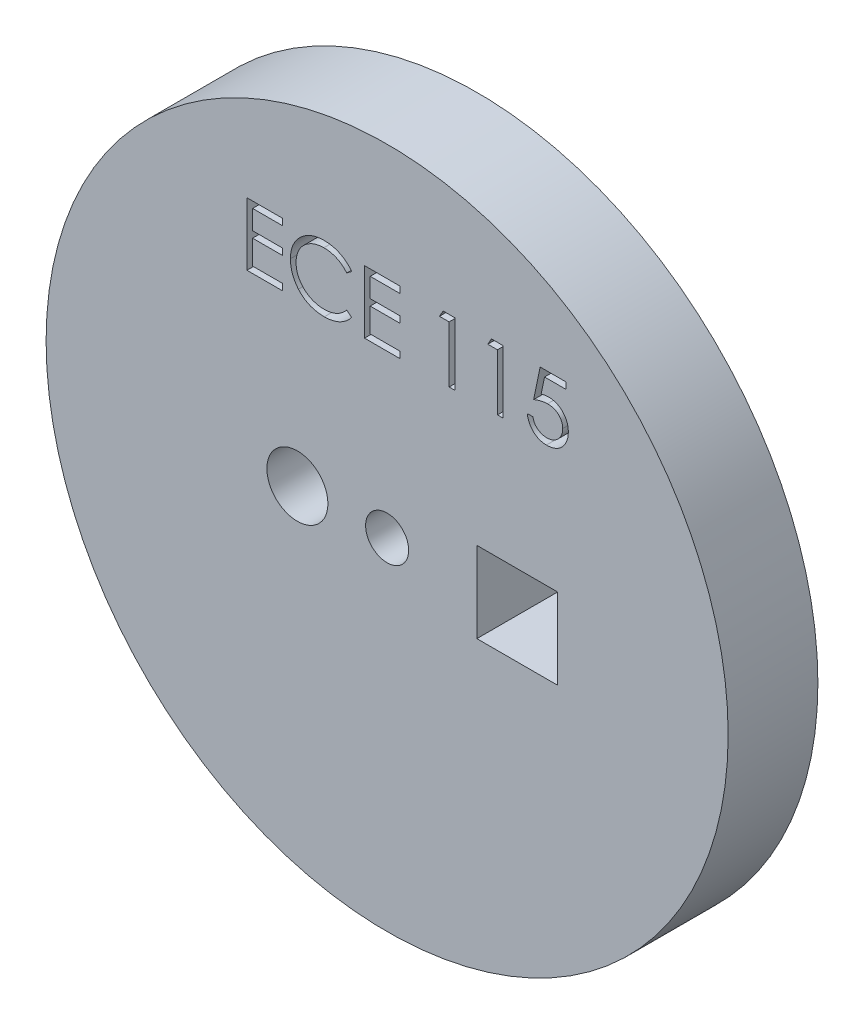
from build123d import *

# Parameters (mm, degrees)
SKETCH1_R           = 19
BOSS_EXTRUDE1_DEPTH = 5
SKETCH3_R           = 1.2
SKETCH3_R_2         = 1.7
SKETCH3_W           = 4.5
SKETCH3_H           = 4.5
CUT_EXTRUDE1_DEPTH  = 5
CUT_EXTRUDE2_DEPTH  = 5


with BuildPart() as part:
    # Sketch1 → Boss-Extrude1 (new body)
    with BuildSketch(Plane.XY):
        Circle(SKETCH1_R)
    extrude(amount=BOSS_EXTRUDE1_DEPTH)

    # Sketch3 → Cut-Extrude1 (cut)
    with BuildSketch(Plane.XY.offset(5)):
        Circle(SKETCH3_R)
        with Locations((-5, 0)):
            Circle(SKETCH3_R_2)
        with Locations((7.25, -0.109758643)):
            Rectangle(SKETCH3_W, SKETCH3_H)
    extrude(amount=-CUT_EXTRUDE1_DEPTH, mode=Mode.SUBTRACT)

    # Sketch4 → Cut-Extrude2 (cut)
    with BuildSketch(Plane.XY.offset(5)):
        Polygon((-7.809310087, 12.508270601), (-5.834951113, 12.508270601), (-5.834951113, 12.149296242), (-7.495207523, 12.149296242), (-7.495207523, 11.072373165), (-5.834951113, 11.072373165), (-5.834951113, 10.713398806), (-7.495207523, 10.713398806), (-7.495207523, 9.36724496), (-5.834951113, 9.36724496), (-5.834951113, 9.008270601), (-7.809310087, 9.008270601), align=None)
        with BuildLine():
            Line((-1.975976754, 11.866043037), (-2.250816497, 11.655706498))
            add(Edge.make_bspline(
                [(-2.250816497, 11.655706498), (-2.270422386, 11.679072468), (-2.309369832, 11.725489384), (-2.372029035, 11.790668928), (-2.437330678, 11.85173419), (-2.505249799, 11.908976069), (-2.577008919, 11.960392835), (-2.650869717, 12.008663938), (-2.728067762, 12.051931676), (-2.834819497, 12.104394662), (-2.974467345, 12.159140817), (-3.150262184, 12.205044048), (-3.333773283, 12.234265224), (-3.458970882, 12.237430066), (-3.522651433, 12.239039832)],
                knots=[0, 0, 0, 0, 9.1485e-05, 0.000181737, 0.000271024, 0.000359627, 0.000447979, 0.000535687, 0.000624217, 0.000713268, 0.000892422, 0.00107303, 0.001257466, 0.001448389, 0.001448389, 0.001448389, 0.001448389], degree=3))
            add(Edge.make_bspline(
                [(-3.522651433, 12.239039832), (-3.557734732, 12.238635869), (-3.627575725, 12.237831693), (-3.731224199, 12.227222568), (-3.83293725, 12.212311358), (-3.932648716, 12.190186035), (-4.030231674, 12.162213416), (-4.126324076, 12.128788002), (-4.219534676, 12.087433162), (-4.311152914, 12.041724902), (-4.398932125, 11.990097457), (-4.481987173, 11.933784105), (-4.560015141, 11.873415009), (-4.633077753, 11.808763903), (-4.701249702, 11.740121942), (-4.764037012, 11.6667576), (-4.821222423, 11.588905427), (-4.873939448, 11.507592019), (-4.921152181, 11.423054228), (-4.960682061, 11.334979157), (-4.995687183, 11.244875054), (-5.023386425, 11.151723893), (-5.045310942, 11.056181128), (-5.060438605, 10.95799034), (-5.070927077, 10.85735666), (-5.071727254, 10.789147347), (-5.0721306, 10.754764992)],
                knots=[0, 0, 0, 0, 0.000105206, 0.000209435, 0.000312261, 0.00041348, 0.000515565, 0.000616682, 0.000718413, 0.000821258, 0.000923708, 0.001023662, 0.001122111, 0.001219464, 0.00131614, 0.001412112, 0.001508869, 0.001605718, 0.001702691, 0.001799013, 0.001895107, 0.001992482, 0.002090281, 0.00218895, 0.002290387, 0.00239349, 0.00239349, 0.00239349, 0.00239349], degree=3))
            add(Edge.make_bspline(
                [(-5.0721306, 10.754764992), (-5.070868781, 10.703033672), (-5.068391366, 10.601466087), (-5.046343032, 10.452695477), (-5.012837941, 10.310174803), (-4.962622364, 10.174794961), (-4.900703314, 10.044886602), (-4.822462702, 9.922647749), (-4.731846165, 9.806231185), (-4.627571745, 9.698388237), (-4.513165929, 9.599874511), (-4.390418018, 9.51312393), (-4.25963373, 9.440809048), (-4.1222571, 9.380633101), (-3.977230986, 9.334376373), (-3.824816183, 9.30181225), (-3.665344188, 9.280570069), (-3.556374788, 9.278536381), (-3.500916657, 9.27750137)],
                knots=[0, 0, 0, 0, 0.000155106, 0.000304531, 0.000450265, 0.000593548, 0.000736853, 0.000881182, 0.001028026, 0.001178769, 0.001330408, 0.001480379, 0.001628835, 0.001777978, 0.001929641, 0.002084627, 0.002245075, 0.00241136, 0.00241136, 0.00241136, 0.00241136], degree=3))
            add(Edge.make_bspline(
                [(-3.500916657, 9.27750137), (-3.439813968, 9.27919015), (-3.31954926, 9.282514072), (-3.143181233, 9.310673322), (-2.974345468, 9.356331239), (-2.813032881, 9.420229162), (-2.659698235, 9.50329445), (-2.514101575, 9.603992327), (-2.376120004, 9.72328066), (-2.293148722, 9.814363788), (-2.250816497, 9.860834703)],
                knots=[0, 0, 0, 0, 0.00018322, 0.00036062, 0.000534275, 0.000707044, 0.000879893, 0.001056289, 0.001237208, 0.001425665, 0.001425665, 0.001425665, 0.001425665], degree=3))
            Line((-2.250816497, 9.860834703), (-1.975976754, 9.65260153))
            add(Edge.make_bspline(
                [(-1.975976754, 9.65260153), (-1.998094863, 9.624063078), (-2.042225139, 9.567122872), (-2.113683156, 9.486851162), (-2.188960453, 9.411347127), (-2.268616163, 9.341219506), (-2.351733955, 9.27506504), (-2.439806267, 9.214763209), (-2.5316753, 9.159472325), (-2.627029778, 9.1088454), (-2.725768391, 9.063928153), (-2.827772826, 9.025474385), (-2.932603402, 8.992349496), (-3.04026491, 8.965097559), (-3.150980667, 8.943826475), (-3.264351141, 8.9296068), (-3.380621016, 8.919864886), (-3.459062437, 8.91897697), (-3.498813292, 8.918527011)],
                knots=[0, 0, 0, 0, 0.000108293, 0.000216068, 0.000322162, 0.000427957, 0.000534281, 0.00064066, 0.000747915, 0.000855806, 0.000964371, 0.001073102, 0.001182643, 0.001294024, 0.001406092, 0.001520624, 0.001636667, 0.001755891, 0.001755891, 0.001755891, 0.001755891], degree=3))
            add(Edge.make_bspline(
                [(-3.498813292, 8.918527011), (-3.536456959, 8.918789004), (-3.610892649, 8.919307062), (-3.720791401, 8.927699229), (-3.827780982, 8.939148966), (-3.931555608, 8.956389097), (-4.032681583, 8.976733437), (-4.130242167, 9.004004694), (-4.225197377, 9.03455386), (-4.317165718, 9.070458847), (-4.406225418, 9.110975029), (-4.492089229, 9.156766588), (-4.574717662, 9.207448453), (-4.654923083, 9.261903463), (-4.731520666, 9.321880765), (-4.805174192, 9.3865474), (-4.876296668, 9.455685411), (-4.920299353, 9.505540264), (-4.942423068, 9.530606338)],
                knots=[0, 0, 0, 0, 0.0001129, 0.000223246, 0.000330481, 0.000435603, 0.000538732, 0.000639764, 0.000739316, 0.000837878, 0.000935767, 0.001032686, 0.001129604, 0.00122645, 0.001323362, 0.001421241, 0.001520399, 0.001620667, 0.001620667, 0.001620667, 0.001620667], degree=3))
            add(Edge.make_bspline(
                [(-4.942423068, 9.530606338), (-4.977858711, 9.574147527), (-5.048302188, 9.660704237), (-5.138427872, 9.800990219), (-5.215575427, 9.947458428), (-5.277951348, 10.100878356), (-5.326714081, 10.260905744), (-5.360495276, 10.427621258), (-5.38244688, 10.6008692), (-5.384957169, 10.718705989), (-5.386233164, 10.778603133)],
                knots=[0, 0, 0, 0, 0.000168306, 0.00033458, 0.000499224, 0.000664315, 0.00083066, 0.00100034, 0.001174094, 0.001353718, 0.001353718, 0.001353718, 0.001353718], degree=3))
            add(Edge.make_bspline(
                [(-5.386233164, 10.778603133), (-5.38467797, 10.841558586), (-5.381618224, 10.965419511), (-5.355622429, 11.147193464), (-5.313803632, 11.321344863), (-5.254406744, 11.487548608), (-5.179101393, 11.646678888), (-5.086074779, 11.797520093), (-4.976407636, 11.941036893), (-4.850960069, 12.075051644), (-4.713392733, 12.197590996), (-4.56607392, 12.3053972), (-4.409291973, 12.395114716), (-4.244774121, 12.470110879), (-4.071288439, 12.527755342), (-3.88920507, 12.568108528), (-3.698866155, 12.593225645), (-3.56900373, 12.596400853), (-3.503020023, 12.598014191)],
                knots=[0, 0, 0, 0, 0.000188789, 0.000371431, 0.000549644, 0.000725278, 0.00089996, 0.001076844, 0.001255917, 0.001440951, 0.001626689, 0.001807878, 0.001987546, 0.002167657, 0.002349462, 0.002534866, 0.002726448, 0.002924344, 0.002924344, 0.002924344, 0.002924344], degree=3))
            add(Edge.make_bspline(
                [(-3.503020023, 12.598014191), (-3.462805551, 12.597532052), (-3.383205054, 12.596577708), (-3.265452401, 12.587271566), (-3.150810074, 12.57175796), (-3.039199092, 12.55064189), (-2.930076476, 12.524434569), (-2.824276235, 12.490294271), (-2.721177548, 12.451257739), (-2.62143064, 12.406299273), (-2.52551409, 12.355832532), (-2.433457771, 12.300416908), (-2.345992913, 12.240121103), (-2.262504064, 12.175457927), (-2.184387853, 12.105059368), (-2.109426375, 12.030861772), (-2.040165297, 11.950727948), (-1.997412102, 11.894323014), (-1.975976754, 11.866043037)],
                knots=[0, 0, 0, 0, 0.000120626, 0.000238766, 0.000354085, 0.000467531, 0.000579423, 0.000690512, 0.000800803, 0.000910007, 0.001018518, 0.001125773, 0.001232152, 0.001337058, 0.001442329, 0.001547432, 0.001653292, 0.001759736, 0.001759736, 0.001759736, 0.001759736], degree=3))
        make_face()
        Polygon((-1.258028036, 12.508270601), (0.716330939, 12.508270601), (0.716330939, 12.149296242), (-0.943925472, 12.149296242), (-0.943925472, 11.072373165), (0.716330939, 11.072373165), (0.716330939, 10.713398806), (-0.943925472, 10.713398806), (-0.943925472, 9.36724496), (0.716330939, 9.36724496), (0.716330939, 9.008270601), (-1.258028036, 9.008270601), align=None)
        Polygon((3.120477573, 12.508270601), (3.76761299, 12.508270601), (3.76761299, 9.008270601), (3.453510426, 9.008270601), (3.453510426, 12.149296242), (2.915048887, 12.149296242), align=None)
        Polygon((5.812785266, 12.508270601), (6.459920682, 12.508270601), (6.459920682, 9.008270601), (6.145818118, 9.008270601), (6.145818118, 12.149296242), (5.60735658, 12.149296242), align=None)
        with BuildLine():
            Line((9.959920682, 12.508270601), (9.959920682, 12.149296242))
            Line((9.959920682, 12.149296242), (8.769415875, 12.149296242))
            Line((8.769415875, 12.149296242), (8.580814112, 11.228723325))
            add(Edge.make_bspline(
                [(8.580814112, 11.228723325), (8.617869986, 11.238953597), (8.689659882, 11.258773131), (8.795619743, 11.280778901), (8.896211946, 11.294044345), (8.961487317, 11.295855656), (8.993073727, 11.296732139)],
                knots=[0, 0, 0, 0, 0.000115302, 0.000223379, 0.000324431, 0.000419176, 0.000419176, 0.000419176, 0.000419176], degree=3))
            add(Edge.make_bspline(
                [(8.993073727, 11.296732139), (9.032157467, 11.295886204), (9.109005864, 11.294222883), (9.221444811, 11.278251033), (9.328777704, 11.253111119), (9.430780075, 11.217990597), (9.527640625, 11.173080864), (9.618468187, 11.116980923), (9.7046261, 11.051447592), (9.784568694, 10.97610258), (9.857093002, 10.893180964), (9.920858991, 10.804023092), (9.975021582, 10.70949543), (10.018582337, 10.608694822), (10.053366671, 10.502735668), (10.076518666, 10.390503086), (10.091935375, 10.273054966), (10.093657761, 10.192750396), (10.094536067, 10.151800248)],
                knots=[0, 0, 0, 0, 0.00011719, 0.000230425, 0.000339944, 0.000447481, 0.000553499, 0.000659556, 0.000767111, 0.000877722, 0.000988528, 0.001097091, 0.001206056, 0.001314692, 0.001425996, 0.001539995, 0.001658004, 0.001780798, 0.001780798, 0.001780798, 0.001780798], degree=3))
            add(Edge.make_bspline(
                [(10.094536067, 10.151800248), (10.093870992, 10.123278028), (10.092549829, 10.06661904), (10.085831241, 9.98247484), (10.072895525, 9.900112007), (10.055527801, 9.819519615), (10.032985383, 9.740850243), (10.005696329, 9.663878715), (9.972300302, 9.589084108), (9.935668927, 9.515758713), (9.894422449, 9.445560206), (9.848643941, 9.379911219), (9.80027845, 9.317826938), (9.748237064, 9.259973205), (9.692036069, 9.206730187), (9.632356103, 9.157781905), (9.569673383, 9.112300575), (9.503018141, 9.07213238), (9.433875658, 9.035169424), (9.361247441, 9.004845886), (9.286786741, 8.977735358), (9.209421865, 8.956125831), (9.129328052, 8.939193276), (9.046373277, 8.927692676), (8.960992607, 8.919316238), (8.903117594, 8.918791881), (8.873883022, 8.918527011)],
                knots=[0, 0, 0, 0, 8.5583e-05, 0.000170009, 0.000253005, 0.000335518, 0.000417186, 0.000498352, 0.000580291, 0.000662755, 0.000744161, 0.000824288, 0.000902692, 0.000980133, 0.001057498, 0.001134702, 0.00121156, 0.001289599, 0.001368002, 0.001446531, 0.001525481, 0.001605609, 0.001687289, 0.001770875, 0.001856759, 0.001944425, 0.001944425, 0.001944425, 0.001944425], degree=3))
            add(Edge.make_bspline(
                [(8.873883022, 8.918527011), (8.839008841, 8.919217849), (8.770398011, 8.920576991), (8.669877444, 8.934795477), (8.573162838, 8.955159393), (8.481032737, 8.985795663), (8.392661473, 9.024182957), (8.309238755, 9.072699129), (8.228632979, 9.127678233), (8.154120942, 9.192558586), (8.084964829, 9.263474268), (8.02305832, 9.340431909), (7.967924743, 9.422161351), (7.920446996, 9.509059505), (7.879948975, 9.600898036), (7.848133987, 9.698021037), (7.822455632, 9.799921041), (7.811592211, 9.870074551), (7.806074528, 9.905706498)],
                knots=[0, 0, 0, 0, 0.000104552, 0.000205693, 0.000304023, 0.000400691, 0.00049644, 0.000592535, 0.000689779, 0.000788716, 0.000888377, 0.000986596, 0.001084603, 0.001183757, 0.001283279, 0.001385267, 0.001490017, 0.001598135, 0.001598135, 0.001598135, 0.001598135], degree=3))
            Line((7.806074528, 9.905706498), (8.120177093, 9.905706498))
            add(Edge.make_bspline(
                [(8.120177093, 9.905706498), (8.12790565, 9.872330046), (8.142760366, 9.808178651), (8.175366115, 9.71804731), (8.215231991, 9.637728086), (8.262636339, 9.566158503), (8.319186369, 9.503749505), (8.383715798, 9.448132444), (8.456063522, 9.397957314), (8.536456751, 9.356134547), (8.62126983, 9.320465794), (8.71003704, 9.296714099), (8.800341387, 9.280013206), (8.861419757, 9.278341445), (8.892112189, 9.27750137)],
                knots=[0, 0, 0, 0, 0.000102709, 0.000197412, 0.000286774, 0.000371169, 0.000454082, 0.000538572, 0.000626283, 0.000717552, 0.000809994, 0.00090168, 0.00099274, 0.001084718, 0.001084718, 0.001084718, 0.001084718], degree=3))
            add(Edge.make_bspline(
                [(8.892112189, 9.27750137), (8.922070633, 9.278322148), (8.981059055, 9.279938266), (9.067870442, 9.292377279), (9.151683316, 9.31153485), (9.231670673, 9.340204705), (9.309232213, 9.375049423), (9.382405983, 9.419764499), (9.45330886, 9.471224518), (9.519736994, 9.530181148), (9.580576443, 9.595150842), (9.634332564, 9.664628236), (9.679109477, 9.738745082), (9.716843586, 9.816218235), (9.745496885, 9.897896792), (9.765937866, 9.983397967), (9.777940925, 10.072932948), (9.779592105, 10.134002257), (9.780433503, 10.165121562)],
                knots=[0, 0, 0, 0, 8.9842e-05, 0.0001769, 0.000262612, 0.000347317, 0.000431396, 0.000517249, 0.000604055, 0.000693954, 0.000783242, 0.000870748, 0.000956963, 0.001042571, 0.001128832, 0.00121607, 0.001305907, 0.001399251, 0.001399251, 0.001399251, 0.001399251], degree=3))
            add(Edge.make_bspline(
                [(9.780433503, 10.165121562), (9.779775023, 10.193197314), (9.778486143, 10.248151603), (9.767955573, 10.32855081), (9.749638601, 10.404623852), (9.724214721, 10.476738086), (9.691935213, 10.544961528), (9.652488901, 10.609364588), (9.605135503, 10.669098422), (9.551043614, 10.724190975), (9.491785573, 10.77503585), (9.426341831, 10.818379937), (9.356081904, 10.854843854), (9.281852304, 10.886311853), (9.201887406, 10.908912598), (9.117770774, 10.925880483), (9.028594066, 10.935695846), (8.967623377, 10.937057734), (8.936282862, 10.93775778)],
                knots=[0, 0, 0, 0, 8.4208e-05, 0.000164824, 0.000242709, 0.000318547, 0.000393815, 0.000468731, 0.000544614, 0.00062196, 0.000700062, 0.000778428, 0.000856831, 0.000937299, 0.001019835, 0.001105635, 0.00119452, 0.001288536, 0.001288536, 0.001288536, 0.001288536], degree=3))
            add(Edge.make_bspline(
                [(8.936282862, 10.93775778), (8.909153933, 10.937177189), (8.853139578, 10.935978416), (8.767216751, 10.927151919), (8.676925028, 10.912912625), (8.582610532, 10.893326377), (8.483990024, 10.8676953), (8.381271624, 10.8369808), (8.274239357, 10.800258801), (8.202121633, 10.772526587), (8.165048887, 10.758270601)],
                knots=[0, 0, 0, 0, 8.1378e-05, 0.000168026, 0.000258858, 0.000355524, 0.000456875, 0.000564457, 0.000677092, 0.000796243, 0.000796243, 0.000796243, 0.000796243], degree=3))
            Line((8.165048887, 10.758270601), (8.524023246, 12.508270601))
            Line((8.524023246, 12.508270601), (9.959920682, 12.508270601))
        make_face()
    extrude(amount=-CUT_EXTRUDE2_DEPTH, mode=Mode.SUBTRACT)


solid = part.part
